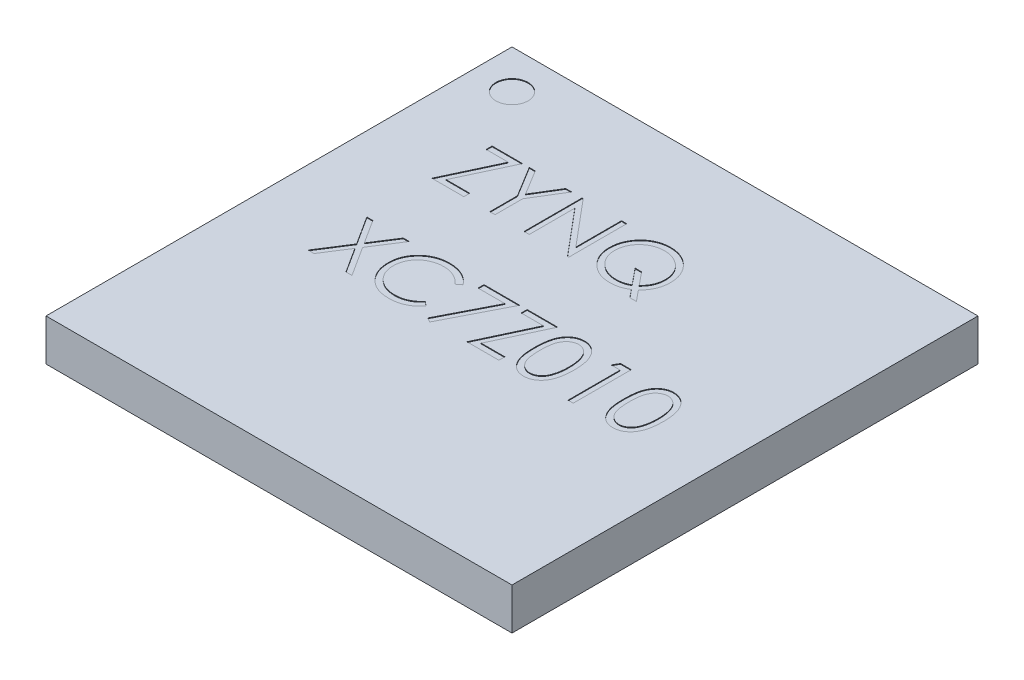
from build123d import *

# Parameters (mm, degrees)
SKETCH1_W           = 17.00022
SKETCH1_H           = 17.00022
BOSS_EXTRUDE1_DEPTH = 1.52
SKETCH2_R           = 0.585111635
CUT_EXTRUDE1_DEPTH  = 0.0254


with BuildPart() as part:
    # Sketch1 → Boss-Extrude1 (new body)
    with BuildSketch(Plane(origin=(0, 0, 0), x_dir=(1, 0, 0), z_dir=(0, 1, 0))):
        with Locations((8.50011, 8.50011)):
            Rectangle(SKETCH1_W, SKETCH1_H)
    extrude(amount=BOSS_EXTRUDE1_DEPTH)

    # Sketch2 → Cut-Extrude1 (cut)
    with BuildSketch(Plane(origin=(0, 1.52, 0), x_dir=(1, 0, 0), z_dir=(0, 1, 0))):
        with Locations((1.413411419, 15.586808581)):
            Circle(SKETCH2_R)
        Polygon((2.767351201, 13.289195865), (2.767351201, 13.506289882), (3.879958038, 13.506289882), (2.992077429, 11.606717233), (3.852821286, 11.606717233), (3.852821286, 11.389623216), (2.685940944, 11.389623216), (3.573821553, 13.289195865), align=None)
        Polygon((4.124188808, 13.506289882), (4.341706836, 13.506289882), (4.898010255, 12.596784674), (5.45346565, 13.506289882), (5.670983679, 13.506289882), (4.992564876, 12.395803104), (4.992564876, 11.389623216), (4.802607611, 11.389623216), (4.802607611, 12.395803104), align=None)
        Polygon((6.050898209, 11.389623216), (6.050898209, 13.506289882), (6.090755314, 13.506289882), (7.489146072, 11.840347708), (7.489146072, 13.506289882), (7.679103337, 13.506289882), (7.679103337, 11.389623216), (7.635854139, 11.389623216), (6.240855474, 13.051749284), (6.240855474, 11.389623216), align=None)
        with BuildLine():
            Line((9.986151281, 11.62537375), (10.311368295, 11.226802703))
            Line((10.311368295, 11.226802703), (10.074345725, 11.226802703))
            Line((10.074345725, 11.226802703), (9.839443215, 11.514282671))
            add(Edge.make_bspline(
                [(9.839443215, 11.514282671), (9.815883449, 11.499965697), (9.769197908, 11.471595481), (9.69640475, 11.435027847), (9.622163998, 11.404598805), (9.546639914, 11.379458868), (9.469942504, 11.359335824), (9.391682844, 11.34536958), (9.312144773, 11.337259556), (9.258706559, 11.335988753), (9.231834374, 11.335349711)],
                knots=[0, 0, 0, 0, 8.2682e-05, 0.000163842, 0.000244078, 0.000323188, 0.000402479, 0.000481742, 0.000561441, 0.000642058, 0.000642058, 0.000642058, 0.000642058], degree=3))
            add(Edge.make_bspline(
                [(9.231834374, 11.335349711), (9.193335025, 11.336277021), (9.117579767, 11.33810169), (9.006321648, 11.354031395), (8.899530602, 11.378633423), (8.797419487, 11.414230111), (8.69987707, 11.459697612), (8.606948667, 11.515752555), (8.518587047, 11.581618514), (8.436096562, 11.656865034), (8.360667381, 11.738722766), (8.294483001, 11.826184061), (8.238208396, 11.917797603), (8.192707025, 12.014020241), (8.156595607, 12.114014288), (8.131986654, 12.218611363), (8.116057566, 12.327188817), (8.114222496, 12.40111683), (8.113291372, 12.43862829)],
                knots=[0, 0, 0, 0, 0.000115443, 0.000227158, 0.000336486, 0.000443762, 0.000550937, 0.000658777, 0.000768766, 0.000881029, 0.000993265, 0.001102237, 0.001209571, 0.001315212, 0.001421029, 0.001527882, 0.001637077, 0.001749555, 0.001749555, 0.001749555, 0.001749555], degree=3))
            add(Edge.make_bspline(
                [(8.113291372, 12.43862829), (8.113622656, 12.463805305), (8.114282896, 12.513982444), (8.121920526, 12.588299924), (8.133268152, 12.661393946), (8.149318928, 12.73296076), (8.170330732, 12.80329371), (8.195521717, 12.872254108), (8.226043947, 12.939664261), (8.260548588, 13.005386203), (8.299031161, 13.068850317), (8.3409511, 13.129153339), (8.386411534, 13.18570098), (8.435380279, 13.238467367), (8.48766177, 13.28756914), (8.542806428, 13.333814859), (8.601990046, 13.375484133), (8.663650587, 13.414234887), (8.728133836, 13.448310808), (8.794178502, 13.478773594), (8.862278634, 13.503490305), (8.931550628, 13.524551938), (9.002414749, 13.540631293), (9.07481577, 13.551895732), (9.148702755, 13.559607031), (9.198600233, 13.560242655), (9.22377815, 13.560563387)],
                knots=[0, 0, 0, 0, 7.5504e-05, 0.000150477, 0.000223882, 0.000297329, 0.00037031, 0.000443958, 0.000517405, 0.000592132, 0.000666523, 0.000739921, 0.000812299, 0.000884008, 0.000955696, 0.001027357, 0.001099716, 0.001172662, 0.001245692, 0.001318366, 0.001390673, 0.001462843, 0.001535463, 0.001608448, 0.001682577, 0.001758081, 0.001758081, 0.001758081, 0.001758081], degree=3))
            add(Edge.make_bspline(
                [(9.22377815, 13.560563387), (9.262277643, 13.559640733), (9.337893111, 13.557828581), (9.448875606, 13.541896474), (9.555352051, 13.517195723), (9.657246645, 13.481780445), (9.754468542, 13.43619844), (9.846976897, 13.380154795), (9.934915134, 13.314284473), (10.01697458, 13.239032915), (10.092226111, 13.156973473), (10.158096537, 13.069035247), (10.214139803, 12.976526843), (10.259723207, 12.87930513), (10.295133222, 12.77740984), (10.319885779, 12.670799494), (10.335741814, 12.559664263), (10.337573945, 12.483910876), (10.338505047, 12.445412479)],
                knots=[0, 0, 0, 0, 0.000115443, 0.000226738, 0.000335653, 0.000442929, 0.00054972, 0.000657197, 0.000766846, 0.000878796, 0.000990745, 0.001100395, 0.001207872, 0.001314663, 0.001421939, 0.001530854, 0.001642568, 0.001758012, 0.001758012, 0.001758012, 0.001758012], degree=3))
            add(Edge.make_bspline(
                [(10.338505047, 12.445412479), (10.337487464, 12.405354643), (10.335486444, 12.326583177), (10.31845742, 12.211073214), (10.29107774, 12.100733989), (10.252250047, 11.995637797), (10.202054614, 11.89580374), (10.141461181, 11.800233467), (10.069740195, 11.708933755), (10.014307686, 11.653520417), (9.986151281, 11.62537375)],
                knots=[0, 0, 0, 0, 0.000120122, 0.000236213, 0.000349437, 0.000460652, 0.000571582, 0.000684037, 0.000799659, 0.000919012, 0.000919012, 0.000919012, 0.000919012], degree=3))
        make_face()
        with BuildLine():
            add(Edge.make_bspline(
                [(9.858523743, 11.781834086), (9.881618803, 11.805288551), (9.927047809, 11.851424523), (9.98599105, 11.927085076), (10.036688151, 12.005732688), (10.0772767, 12.088413558), (10.109570424, 12.174091818), (10.131881841, 12.263446348), (10.14585189, 12.356070364), (10.147642544, 12.419074069), (10.148547782, 12.450924631)],
                knots=[0, 0, 0, 0, 9.8678e-05, 0.000194104, 0.000287145, 0.000378924, 0.00046989, 0.000561313, 0.000654738, 0.000750255, 0.000750255, 0.000750255, 0.000750255], degree=3))
            add(Edge.make_bspline(
                [(10.148547782, 12.450924631), (10.148311257, 12.471435998), (10.147843688, 12.511983355), (10.141414631, 12.571986329), (10.132319427, 12.63066406), (10.11915236, 12.687911706), (10.102196413, 12.743613281), (10.081254329, 12.79769317), (10.056734131, 12.850325837), (10.028148938, 12.901184332), (9.996636182, 12.950194941), (9.961558618, 12.996758288), (9.923409983, 13.040634279), (9.882607033, 13.082545969), (9.838363089, 13.121629404), (9.790836826, 13.157867831), (9.740613874, 13.19213821), (9.68744571, 13.223071651), (9.632655933, 13.251510123), (9.576565138, 13.276136079), (9.519644304, 13.296993382), (9.461981574, 13.313905976), (9.403651566, 13.327218342), (9.344552014, 13.336303368), (9.28483575, 13.342725805), (9.244713142, 13.343221303), (9.224626174, 13.34346937)],
                knots=[0, 0, 0, 0, 6.1505e-05, 0.000121585, 0.000180837, 0.000239569, 0.000297646, 0.000355364, 0.000413409, 0.000471684, 0.000530255, 0.00058809, 0.000646406, 0.000704575, 0.00076345, 0.000823324, 0.000883772, 0.00094573, 0.001007742, 0.001068876, 0.001129373, 0.001189481, 0.00124904, 0.001308711, 0.001368791, 0.001429024, 0.001429024, 0.001429024, 0.001429024], degree=3))
            add(Edge.make_bspline(
                [(9.224626174, 13.34346937), (9.204398242, 13.343219572), (9.163994336, 13.34272062), (9.103989772, 13.33633889), (9.044754586, 13.32720834), (8.986549307, 13.313962139), (8.92916781, 13.297016654), (8.872788201, 13.276033258), (8.816920174, 13.252015552), (8.762723044, 13.223595238), (8.710291635, 13.1923958), (8.660426048, 13.158466181), (8.613809655, 13.121467864), (8.570000254, 13.081996518), (8.529107267, 13.039747593), (8.490937617, 12.995002126), (8.45616163, 12.947240934), (8.424300284, 12.897318539), (8.396139716, 12.845180701), (8.370742456, 12.791768112), (8.35011424, 12.736491904), (8.333178912, 12.679794507), (8.319340185, 12.621816875), (8.310420589, 12.562222449), (8.303943307, 12.501383255), (8.303481976, 12.460270843), (8.303248637, 12.439476314)],
                knots=[0, 0, 0, 0, 6.0657e-05, 0.000121159, 0.00018083, 0.000240388, 0.00030009, 0.000360189, 0.000420765, 0.0004824, 0.000543628, 0.000603726, 0.000663192, 0.000722033, 0.000780505, 0.000839466, 0.000898323, 0.000957607, 0.001016996, 0.001075988, 0.001134895, 0.001193784, 0.001253437, 0.001313528, 0.001374451, 0.001436804, 0.001436804, 0.001436804, 0.001436804], degree=3))
            add(Edge.make_bspline(
                [(8.303248637, 12.439476314), (8.304043026, 12.408903839), (8.305605834, 12.348758323), (8.318561131, 12.260454325), (8.340282311, 12.175916781), (8.370671144, 12.09502475), (8.408820156, 12.017311985), (8.456261337, 11.943539812), (8.512792289, 11.873989219), (8.576274423, 11.808182488), (8.646105717, 11.748564225), (8.720133662, 11.696093644), (8.797726225, 11.651577005), (8.879127058, 11.615646883), (8.963729154, 11.58679378), (9.052200359, 11.567259653), (9.143962334, 11.554311908), (9.206489519, 11.553072289), (9.23819455, 11.552443729)],
                knots=[0, 0, 0, 0, 9.1685e-05, 0.000180372, 0.000267067, 0.00035307, 0.00043916, 0.000526315, 0.000615579, 0.000707637, 0.000800262, 0.000890612, 0.000979493, 0.001068136, 0.001157169, 0.001247173, 0.001339582, 0.001434637, 0.001434637, 0.001434637, 0.001434637], degree=3))
            add(Edge.make_bspline(
                [(9.23819455, 11.552443729), (9.259977109, 11.552681019), (9.303061471, 11.553150364), (9.366594131, 11.559549119), (9.428572082, 11.568555499), (9.488421392, 11.58225332), (9.546661046, 11.599282724), (9.602944386, 11.619997457), (9.657569973, 11.644554947), (9.692303305, 11.663982812), (9.709695618, 11.67371109)],
                knots=[0, 0, 0, 0, 6.532e-05, 0.000129198, 0.000191383, 0.000253103, 0.000313211, 0.00037331, 0.000432895, 0.000492657, 0.000492657, 0.000492657, 0.000492657], degree=3))
            Line((9.709695618, 11.67371109), (9.233106409, 12.257999284))
            Line((9.233106409, 12.257999284), (9.470128978, 12.257999284))
            Line((9.470128978, 12.257999284), (9.858523743, 11.781834086))
        make_face(mode=Mode.SUBTRACT)
        Polygon((2.726646072, 8.978512105), (2.945860148, 8.978512105), (3.500043508, 8.112680107), (4.054226868, 8.978512105), (4.273440944, 8.978512105), (3.609862552, 7.941379359), (4.300577696, 6.861845438), (4.081363621, 6.861845438), (3.500043508, 7.770078611), (2.918723396, 6.861845438), (2.69950932, 6.861845438), (3.390648476, 7.941379359), align=None)
        with BuildLine():
            Line((6.620770004, 8.59011734), (6.454557397, 8.462913814))
            add(Edge.make_bspline(
                [(6.454557397, 8.462913814), (6.442700503, 8.477044662), (6.419146571, 8.505115845), (6.381252672, 8.54453395), (6.341760726, 8.581463894), (6.300685829, 8.616081602), (6.257288647, 8.647176503), (6.21262045, 8.676369028), (6.165934013, 8.702535707), (6.101374631, 8.734263323), (6.016920932, 8.767371712), (5.91060691, 8.795132237), (5.799626389, 8.812804091), (5.72391165, 8.814718067), (5.685400079, 8.815691592)],
                knots=[0, 0, 0, 0, 5.5327e-05, 0.000109907, 0.000163905, 0.000217489, 0.000270921, 0.000323963, 0.000377503, 0.000431357, 0.000539703, 0.000648928, 0.000760468, 0.000875931, 0.000875931, 0.000875931, 0.000875931], degree=3))
            add(Edge.make_bspline(
                [(5.685400079, 8.815691592), (5.664183036, 8.815447291), (5.621945864, 8.814960956), (5.559263216, 8.808544961), (5.497751037, 8.799527229), (5.437449341, 8.786146677), (5.378434885, 8.769229902), (5.320321861, 8.749015485), (5.263951641, 8.724005653), (5.208544421, 8.696363039), (5.155458898, 8.665140727), (5.105230369, 8.631084557), (5.058042027, 8.594575628), (5.013856542, 8.555477101), (4.972628745, 8.513965059), (4.934657371, 8.4695971), (4.900073814, 8.422515071), (4.868192565, 8.37333982), (4.839640103, 8.322214584), (4.815733938, 8.268950136), (4.794564173, 8.214458607), (4.777812726, 8.158124334), (4.764553614, 8.100343709), (4.755404979, 8.040961661), (4.749061952, 7.980102245), (4.748578035, 7.938851851), (4.748334107, 7.918058713)],
                knots=[0, 0, 0, 0, 6.3624e-05, 0.000126658, 0.000188844, 0.000250057, 0.000311794, 0.000372946, 0.000434469, 0.000496666, 0.000558624, 0.000619072, 0.00067861, 0.000737485, 0.000795951, 0.000853991, 0.000912506, 0.000971077, 0.001029722, 0.001087974, 0.001146089, 0.001204978, 0.001264122, 0.001323793, 0.001385139, 0.001447492, 0.001447492, 0.001447492, 0.001447492], degree=3))
            add(Edge.make_bspline(
                [(4.748334107, 7.918058713), (4.749097207, 7.886773581), (4.750595453, 7.825349375), (4.763929445, 7.735378577), (4.784192048, 7.649187503), (4.814560516, 7.567314932), (4.852006799, 7.488751306), (4.89932374, 7.414825904), (4.95412517, 7.3444216), (5.017186366, 7.279202294), (5.086374645, 7.219624946), (5.160607906, 7.167161499), (5.239701261, 7.123428213), (5.322781414, 7.087036093), (5.410487683, 7.059061786), (5.502662349, 7.039368245), (5.599104937, 7.026521783), (5.665005478, 7.025291886), (5.698544443, 7.024665951)],
                knots=[0, 0, 0, 0, 9.3802e-05, 0.000184169, 0.000272303, 0.000358955, 0.000445621, 0.000532905, 0.000621711, 0.000712875, 0.00080458, 0.000895277, 0.000985057, 0.001075253, 0.001166973, 0.001260703, 0.001357736, 0.001458299, 0.001458299, 0.001458299, 0.001458299], degree=3))
            add(Edge.make_bspline(
                [(5.698544443, 7.024665951), (5.735497022, 7.02568726), (5.808228536, 7.027697442), (5.9148892, 7.044727083), (6.016994639, 7.072339253), (6.114550346, 7.110982282), (6.207281299, 7.161217004), (6.295332612, 7.222115244), (6.37877861, 7.294256283), (6.428956481, 7.349339889), (6.454557397, 7.377443729)],
                knots=[0, 0, 0, 0, 0.000110804, 0.000218089, 0.000323109, 0.000427593, 0.000532126, 0.000638803, 0.000748216, 0.000862188, 0.000862188, 0.000862188, 0.000862188], degree=3))
            Line((6.454557397, 7.377443729), (6.620770004, 7.251512238))
            add(Edge.make_bspline(
                [(6.620770004, 7.251512238), (6.607393814, 7.23425327), (6.580705505, 7.199818002), (6.537490418, 7.15127273), (6.491965576, 7.105610766), (6.443792837, 7.063200252), (6.393526363, 7.023192551), (6.340263584, 6.986724301), (6.284704693, 6.95328648), (6.227037937, 6.922669245), (6.167324585, 6.895505005), (6.105636189, 6.872249631), (6.04223865, 6.85221696), (5.977129071, 6.835736027), (5.910172399, 6.822872086), (5.841610256, 6.814272568), (5.771294664, 6.808381029), (5.723856281, 6.807844052), (5.699816478, 6.807571934)],
                knots=[0, 0, 0, 0, 6.5492e-05, 0.00013067, 0.000194831, 0.000258812, 0.000323113, 0.000387446, 0.000452311, 0.000517559, 0.000583215, 0.000648971, 0.000715217, 0.000782576, 0.000850351, 0.000919615, 0.000989794, 0.001061896, 0.001061896, 0.001061896, 0.001061896], degree=3))
            add(Edge.make_bspline(
                [(5.699816478, 6.807571934), (5.677051023, 6.807730377), (5.632035153, 6.808043678), (5.565572575, 6.813118942), (5.500869352, 6.820043306), (5.438110412, 6.830469481), (5.376953274, 6.842772963), (5.317952349, 6.85926558), (5.260527055, 6.877740552), (5.204908107, 6.89945452), (5.151048193, 6.923957164), (5.099121031, 6.951650154), (5.049150503, 6.982300615), (5.000645319, 7.015232931), (4.954322019, 7.051504918), (4.909779173, 7.090612835), (4.866767008, 7.13242487), (4.840155861, 7.162575187), (4.826776281, 7.177734193)],
                knots=[0, 0, 0, 0, 6.8278e-05, 0.000135011, 0.000199862, 0.000263436, 0.000325805, 0.000386905, 0.00044711, 0.000506717, 0.000565916, 0.000624529, 0.000683141, 0.00074171, 0.000800319, 0.000859512, 0.00091948, 0.000980118, 0.000980118, 0.000980118, 0.000980118], degree=3))
            add(Edge.make_bspline(
                [(4.826776281, 7.177734193), (4.805346154, 7.204066246), (4.762744622, 7.256412447), (4.708240042, 7.341252064), (4.66158414, 7.429830457), (4.623861559, 7.522612985), (4.594371716, 7.619391453), (4.573942136, 7.720214645), (4.560666642, 7.8249884), (4.559148515, 7.896251601), (4.558376842, 7.932475112)],
                knots=[0, 0, 0, 0, 0.000101785, 0.000202341, 0.000301912, 0.000401753, 0.000502352, 0.000604968, 0.000710047, 0.000818677, 0.000818677, 0.000818677, 0.000818677], degree=3))
            add(Edge.make_bspline(
                [(4.558376842, 7.932475112), (4.559317364, 7.970548172), (4.561167781, 8.045454541), (4.576889048, 8.155384503), (4.602179463, 8.260704635), (4.638100439, 8.361218328), (4.683642246, 8.457454259), (4.739901198, 8.548677274), (4.806223708, 8.635470767), (4.882089618, 8.716517783), (4.965285102, 8.790624915), (5.054377908, 8.855822), (5.149193657, 8.910079736), (5.248687787, 8.955434558), (5.353605318, 8.990295734), (5.463722403, 9.014699804), (5.578832128, 9.029889679), (5.657367976, 9.031809923), (5.697272408, 9.032785609)],
                knots=[0, 0, 0, 0, 0.000114173, 0.000224627, 0.000332404, 0.00043862, 0.000544262, 0.000651234, 0.000759531, 0.000871432, 0.000983759, 0.001093336, 0.001201992, 0.001310916, 0.001420865, 0.001532991, 0.001648852, 0.001768532, 0.001768532, 0.001768532, 0.001768532], degree=3))
            add(Edge.make_bspline(
                [(5.697272408, 9.032785609), (5.721592589, 9.03249403), (5.769731937, 9.031916879), (5.840944255, 9.026288879), (5.910275567, 9.016906841), (5.977773637, 9.004136646), (6.043766839, 8.988287457), (6.107750794, 8.967640705), (6.170100952, 8.944032898), (6.230424082, 8.91684373), (6.288430758, 8.886323368), (6.344102912, 8.85281011), (6.396998327, 8.816345503), (6.447489202, 8.777239678), (6.494730911, 8.734665311), (6.540064757, 8.689793432), (6.581951219, 8.641331548), (6.607806722, 8.607219993), (6.620770004, 8.59011734)],
                knots=[0, 0, 0, 0, 7.295e-05, 0.000144397, 0.000214137, 0.000282745, 0.000350413, 0.000417596, 0.000484295, 0.000550337, 0.000615961, 0.000680825, 0.000745159, 0.000808602, 0.000872266, 0.000935828, 0.000999848, 0.001064221, 0.001064221, 0.001064221, 0.001064221], degree=3))
        make_face()
        Polygon((7.000684534, 8.978512105), (8.303248637, 8.978512105), (7.190641799, 6.807571934), (7.026549251, 6.897886437), (7.981847728, 8.761418088), (7.000684534, 8.761418088), align=None)
        Polygon((8.574616158, 8.761418088), (8.574616158, 8.978512105), (9.687222996, 8.978512105), (8.799342387, 7.078939455), (9.660086243, 7.078939455), (9.660086243, 6.861845438), (8.493205902, 6.861845438), (9.381086511, 8.761418088), align=None)
        with BuildLine():
            add(Edge.make_bspline(
                [(9.904317013, 7.919330748), (9.904515386, 7.953256311), (9.904900728, 8.019157206), (9.909187535, 8.115184109), (9.916308813, 8.205269617), (9.926068081, 8.289418042), (9.937944384, 8.36765111), (9.953798511, 8.439759748), (9.971828159, 8.506077701), (9.992724162, 8.566821225), (10.016302491, 8.622808693), (10.041965116, 8.675075363), (10.070730491, 8.72354215), (10.100954624, 8.768982624), (10.133860972, 8.810652953), (10.168513098, 8.849141611), (10.206263471, 8.883559065), (10.245828814, 8.914913734), (10.287567342, 8.942399843), (10.330289336, 8.966610118), (10.374288852, 8.987292895), (10.41968602, 9.003555206), (10.466072805, 9.01698748), (10.513611364, 9.026173177), (10.562380189, 9.031952831), (10.595298247, 9.032505383), (10.611992627, 9.032785609)],
                knots=[0, 0, 0, 0, 0.000101771, 0.000197691, 0.000288293, 0.000372812, 0.000451793, 0.000525562, 0.000594175, 0.000657869, 0.000718111, 0.000776326, 0.000832393, 0.000887078, 0.000939923, 0.000991548, 0.001042261, 0.001092987, 0.001142849, 0.001192024, 0.001240207, 0.001288496, 0.001336546, 0.001384942, 0.001433593, 0.001483655, 0.001483655, 0.001483655, 0.001483655], degree=3))
            add(Edge.make_bspline(
                [(10.611992627, 9.032785609), (10.628826464, 9.032490597), (10.662303669, 9.031903911), (10.711797611, 9.026265145), (10.760148132, 9.0169088), (10.807149102, 9.003651829), (10.853186594, 8.98720492), (10.897900516, 8.96659033), (10.941568609, 8.942594063), (10.983496925, 8.914397718), (11.024145764, 8.882960818), (11.062516675, 8.847423394), (11.098613151, 8.808144278), (11.132888217, 8.765543722), (11.164369459, 8.718804647), (11.194349582, 8.668739971), (11.221184099, 8.614474163), (11.247028403, 8.556912642), (11.269336247, 8.494462715), (11.289454405, 8.427476407), (11.305709781, 8.355162494), (11.31924996, 8.277900384), (11.329739492, 8.195406334), (11.337379233, 8.107857182), (11.341414861, 8.015195326), (11.342174866, 7.95184177), (11.342564876, 7.919330748)],
                knots=[0, 0, 0, 0, 5.0486e-05, 0.000100401, 0.000149214, 0.00019808, 0.000246767, 0.00029572, 0.000345635, 0.000396085, 0.000447145, 0.000499655, 0.000552765, 0.000607065, 0.000663516, 0.000721691, 0.000781991, 0.00084502, 0.000910878, 0.000980773, 0.001054728, 0.001133082, 0.00121602, 0.001304122, 0.001396653, 0.001494191, 0.001494191, 0.001494191, 0.001494191], degree=3))
            add(Edge.make_bspline(
                [(11.342564876, 7.919330748), (11.342170822, 7.886961527), (11.341403025, 7.823891421), (11.337424474, 7.731646498), (11.329587587, 7.644561967), (11.319784404, 7.562428973), (11.306206917, 7.485589365), (11.289512364, 7.413777247), (11.270976216, 7.346682499), (11.248095174, 7.284854779), (11.223051554, 7.227431594), (11.195803888, 7.173809081), (11.166612136, 7.123513275), (11.134808466, 7.076946762), (11.100909497, 7.033779669), (11.064189692, 6.994773964), (11.025684148, 6.958989796), (10.984915687, 6.927148097), (10.942333463, 6.899277763), (10.898815354, 6.874353196), (10.853589213, 6.854255328), (10.807679951, 6.836998423), (10.760430891, 6.82381434), (10.711900931, 6.814698246), (10.662336922, 6.808304795), (10.628832166, 6.807817067), (10.611992627, 6.807571934)],
                knots=[0, 0, 0, 0, 9.7114e-05, 0.000189222, 0.000276901, 0.000359365, 0.000437302, 0.000510843, 0.000580501, 0.000645961, 0.000708431, 0.000768353, 0.000826312, 0.000882763, 0.000937395, 0.000990794, 0.001043304, 0.001094959, 0.001145763, 0.001195884, 0.001245223, 0.001294056, 0.001342922, 0.001392151, 0.001442115, 0.001492601, 0.001492601, 0.001492601, 0.001492601], degree=3))
            add(Edge.make_bspline(
                [(10.611992627, 6.807571934), (10.59529871, 6.807853968), (10.562381565, 6.808410084), (10.513606051, 6.814163626), (10.466263811, 6.823413764), (10.420121232, 6.83636571), (10.374941577, 6.852219444), (10.33134049, 6.872874291), (10.288833176, 6.896662038), (10.247533045, 6.923752602), (10.208216166, 6.954790001), (10.170661295, 6.98911888), (10.135811879, 7.027595896), (10.103376021, 7.069613497), (10.072548835, 7.114785124), (10.044191928, 7.163727521), (10.017962888, 7.216246624), (9.993988015, 7.272681741), (9.972731442, 7.333856388), (9.953954971, 7.400470415), (9.939129742, 7.473111776), (9.92644005, 7.551197041), (9.916204828, 7.635061751), (9.909217212, 7.724751436), (9.904898417, 7.820210205), (9.904514351, 7.88568764), (9.904317013, 7.919330748)],
                knots=[0, 0, 0, 0, 5.0062e-05, 9.8713e-05, 0.00014711, 0.000194637, 0.000242383, 0.000290566, 0.000339163, 0.000388437, 0.000438568, 0.000489281, 0.000540906, 0.000594085, 0.000648418, 0.000704852, 0.000763635, 0.000824433, 0.000888666, 0.000957801, 0.001031897, 0.001110945, 0.001195093, 0.001285272, 0.001380769, 0.001481691, 0.001481691, 0.001481691, 0.001481691], degree=3))
        make_face()
        with BuildLine():
            add(Edge.make_bspline(
                [(10.094274278, 7.920178771), (10.094346515, 7.891906939), (10.094486713, 7.837036864), (10.098149272, 7.757303083), (10.103138698, 7.682935312), (10.109574149, 7.613839126), (10.11913117, 7.550248404), (10.129839561, 7.491725786), (10.142871025, 7.438580981), (10.15828944, 7.390449305), (10.17585118, 7.346513916), (10.195025678, 7.305631276), (10.215624306, 7.267318439), (10.238677316, 7.231919542), (10.263784045, 7.199319148), (10.290377397, 7.168940244), (10.319449864, 7.141848737), (10.359668794, 7.109356781), (10.412764758, 7.075780924), (10.479663795, 7.046543051), (10.548406144, 7.028168899), (10.595064281, 7.025832246), (10.618352803, 7.024665951)],
                knots=[0, 0, 0, 0, 8.4807e-05, 0.000164593, 0.000239392, 0.000308416, 0.000372699, 0.000432242, 0.000486849, 0.000536731, 0.000583737, 0.000628692, 0.000672143, 0.000714128, 0.00075526, 0.000795507, 0.000835102, 0.000874304, 0.000950532, 0.001022689, 0.001092723, 0.001162513, 0.001162513, 0.001162513, 0.001162513], degree=3))
            add(Edge.make_bspline(
                [(10.618352803, 7.024665951), (10.641791967, 7.025632228), (10.6886219, 7.027562787), (10.75704091, 7.04618869), (10.823462073, 7.074291697), (10.875515103, 7.107521855), (10.915116451, 7.139168035), (10.94349006, 7.166149275), (10.969532346, 7.19636068), (10.994232077, 7.228956921), (11.016885899, 7.264560757), (11.037485987, 7.303000981), (11.056284011, 7.344384341), (11.066993768, 7.373273659), (11.07246939, 7.388044022)],
                knots=[0, 0, 0, 0, 7.0179e-05, 0.000140213, 0.000211255, 0.000285954, 0.00032456, 0.000363247, 0.000403215, 0.00044409, 0.000485846, 0.000529669, 0.000574832, 0.000622078, 0.000622078, 0.000622078, 0.000622078], degree=3))
            add(Edge.make_bspline(
                [(11.07246939, 7.388044022), (11.078850697, 7.406930579), (11.091807487, 7.445278389), (11.108506036, 7.504764978), (11.121656825, 7.567178079), (11.133488004, 7.632144697), (11.141563423, 7.700143945), (11.148063291, 7.770965424), (11.15189185, 7.844662534), (11.152366437, 7.89473379), (11.152607611, 7.920178771)],
                knots=[0, 0, 0, 0, 5.9802e-05, 0.000121424, 0.000185214, 0.00025109, 0.00031946, 0.000390555, 0.000464431, 0.000540764, 0.000540764, 0.000540764, 0.000540764], degree=3))
            add(Edge.make_bspline(
                [(11.152607611, 7.920178771), (11.152274877, 7.945619637), (11.15162398, 7.995387408), (11.149135997, 8.068272212), (11.142711263, 8.137497953), (11.135575606, 8.203362858), (11.125054429, 8.265502327), (11.113710422, 8.324436559), (11.098469689, 8.379435436), (11.082189635, 8.43136004), (11.063556681, 8.479620436), (11.043045737, 8.524441631), (11.021140197, 8.566040012), (10.997347509, 8.604301448), (10.97195012, 8.639397319), (10.944277697, 8.670623955), (10.91542791, 8.698949169), (10.875019421, 8.731281294), (10.822118303, 8.764247891), (10.756292602, 8.794586231), (10.687790832, 8.812008389), (10.641482124, 8.814464743), (10.618352803, 8.815691592)],
                knots=[0, 0, 0, 0, 7.6333e-05, 0.000149323, 0.000218691, 0.000284855, 0.00034801, 0.000407716, 0.0004648, 0.000519108, 0.000570921, 0.000619874, 0.000666914, 0.00071186, 0.000754942, 0.000796705, 0.000836885, 0.000876087, 0.000951731, 0.001023283, 0.001092802, 0.00116217, 0.00116217, 0.00116217, 0.00116217], degree=3))
            add(Edge.make_bspline(
                [(10.618352803, 8.815691592), (10.594942112, 8.81446305), (10.54807808, 8.812003729), (10.478864317, 8.794651142), (10.412519305, 8.764405206), (10.359758077, 8.731172104), (10.319321406, 8.699519887), (10.290847587, 8.672071889), (10.264149664, 8.642047726), (10.239555388, 8.60914752), (10.21652044, 8.573789893), (10.195365257, 8.535696688), (10.176304776, 8.494674863), (10.158715557, 8.450759209), (10.143250109, 8.402631685), (10.130493283, 8.349552342), (10.118708256, 8.291215864), (10.110365403, 8.227280733), (10.102948751, 8.158167241), (10.098182412, 8.083613815), (10.094474461, 8.003746308), (10.094342342, 7.948592532), (10.094274278, 7.920178771)],
                knots=[0, 0, 0, 0, 7.0213e-05, 0.000140555, 0.000212494, 0.000288137, 0.000327075, 0.000366362, 0.000406609, 0.000447484, 0.00048947, 0.000533125, 0.00057808, 0.000625086, 0.000674968, 0.000729575, 0.000788782, 0.000853424, 0.000922913, 0.000997289, 0.001077499, 0.00116273, 0.00116273, 0.00116273, 0.00116273], degree=3))
        make_face(mode=Mode.SUBTRACT)
        Polygon((11.98239861, 8.978512105), (12.373761457, 8.978512105), (12.373761457, 6.861845438), (12.183804192, 6.861845438), (12.183804192, 8.761418088), (11.858163167, 8.761418088), align=None)
        with BuildLine():
            add(Edge.make_bspline(
                [(13.160727269, 7.919330748), (13.160925642, 7.953256311), (13.161310984, 8.019157206), (13.165597791, 8.115184109), (13.17271907, 8.205269617), (13.182478338, 8.289418042), (13.19435464, 8.36765111), (13.210208768, 8.439759748), (13.228238415, 8.506077701), (13.249134418, 8.566821225), (13.272712748, 8.622808693), (13.298375372, 8.675075363), (13.327140748, 8.72354215), (13.357364881, 8.768982624), (13.390271229, 8.810652953), (13.424923354, 8.849141611), (13.462673727, 8.883559065), (13.50223907, 8.914913734), (13.543977599, 8.942399843), (13.586699592, 8.966610118), (13.630699109, 8.987292895), (13.676096276, 9.003555206), (13.722483061, 9.01698748), (13.770021621, 9.026173177), (13.818790446, 9.031952831), (13.851708504, 9.032505383), (13.868402883, 9.032785609)],
                knots=[0, 0, 0, 0, 0.000101771, 0.000197691, 0.000288293, 0.000372812, 0.000451793, 0.000525562, 0.000594175, 0.000657869, 0.000718111, 0.000776326, 0.000832393, 0.000887078, 0.000939923, 0.000991548, 0.001042261, 0.001092987, 0.001142849, 0.001192024, 0.001240207, 0.001288496, 0.001336546, 0.001384942, 0.001433593, 0.001483655, 0.001483655, 0.001483655, 0.001483655], degree=3))
            add(Edge.make_bspline(
                [(13.868402883, 9.032785609), (13.88523672, 9.032490597), (13.918713926, 9.031903911), (13.968207867, 9.026265145), (14.016558389, 9.0169088), (14.063559358, 9.003651829), (14.10959685, 8.98720492), (14.154310773, 8.96659033), (14.197978865, 8.942594063), (14.239907182, 8.914397718), (14.280556021, 8.882960818), (14.318926932, 8.847423394), (14.355023407, 8.808144278), (14.389298473, 8.765543722), (14.420779715, 8.718804647), (14.450759838, 8.668739971), (14.477594355, 8.614474163), (14.503438659, 8.556912642), (14.525746503, 8.494462715), (14.545864661, 8.427476407), (14.562120037, 8.355162494), (14.575660216, 8.277900384), (14.586149749, 8.195406334), (14.593789489, 8.107857182), (14.597825117, 8.015195326), (14.598585122, 7.95184177), (14.598975132, 7.919330748)],
                knots=[0, 0, 0, 0, 5.0486e-05, 0.000100401, 0.000149214, 0.00019808, 0.000246767, 0.00029572, 0.000345635, 0.000396085, 0.000447145, 0.000499655, 0.000552765, 0.000607065, 0.000663516, 0.000721691, 0.000781991, 0.00084502, 0.000910878, 0.000980773, 0.001054728, 0.001133082, 0.00121602, 0.001304122, 0.001396653, 0.001494191, 0.001494191, 0.001494191, 0.001494191], degree=3))
            add(Edge.make_bspline(
                [(14.598975132, 7.919330748), (14.598581079, 7.886961527), (14.597813282, 7.823891421), (14.59383473, 7.731646498), (14.585997844, 7.644561967), (14.57619466, 7.562428973), (14.562617173, 7.485589365), (14.54592262, 7.413777247), (14.527386473, 7.346682499), (14.504505431, 7.284854779), (14.479461811, 7.227431594), (14.452214144, 7.173809081), (14.423022392, 7.123513275), (14.391218723, 7.076946762), (14.357319754, 7.033779669), (14.320599948, 6.994773964), (14.282094404, 6.958989796), (14.241325943, 6.927148097), (14.198743719, 6.899277763), (14.155225611, 6.874353196), (14.109999469, 6.854255328), (14.064090207, 6.836998423), (14.016841148, 6.82381434), (13.968311188, 6.814698246), (13.918747178, 6.808304795), (13.885242422, 6.807817067), (13.868402883, 6.807571934)],
                knots=[0, 0, 0, 0, 9.7114e-05, 0.000189222, 0.000276901, 0.000359365, 0.000437302, 0.000510843, 0.000580501, 0.000645961, 0.000708431, 0.000768353, 0.000826312, 0.000882763, 0.000937395, 0.000990794, 0.001043304, 0.001094959, 0.001145763, 0.001195884, 0.001245223, 0.001294056, 0.001342922, 0.001392151, 0.001442115, 0.001492601, 0.001492601, 0.001492601, 0.001492601], degree=3))
            add(Edge.make_bspline(
                [(13.868402883, 6.807571934), (13.851708967, 6.807853968), (13.818791822, 6.808410084), (13.770016307, 6.814163626), (13.722674068, 6.823413764), (13.676531488, 6.83636571), (13.631351834, 6.852219444), (13.587750746, 6.872874291), (13.545243433, 6.896662038), (13.503943301, 6.923752602), (13.464626423, 6.954790001), (13.427071552, 6.98911888), (13.392222136, 7.027595896), (13.359786278, 7.069613497), (13.328959091, 7.114785124), (13.300602184, 7.163727521), (13.274373144, 7.216246624), (13.250398271, 7.272681741), (13.229141698, 7.333856388), (13.210365227, 7.400470415), (13.195539999, 7.473111776), (13.182850307, 7.551197041), (13.172615085, 7.635061751), (13.165627469, 7.724751436), (13.161308673, 7.820210205), (13.160924607, 7.88568764), (13.160727269, 7.919330748)],
                knots=[0, 0, 0, 0, 5.0062e-05, 9.8713e-05, 0.00014711, 0.000194637, 0.000242383, 0.000290566, 0.000339163, 0.000388437, 0.000438568, 0.000489281, 0.000540906, 0.000594085, 0.000648418, 0.000704852, 0.000763635, 0.000824433, 0.000888666, 0.000957801, 0.001031897, 0.001110945, 0.001195093, 0.001285272, 0.001380769, 0.001481691, 0.001481691, 0.001481691, 0.001481691], degree=3))
        make_face()
        with BuildLine():
            add(Edge.make_bspline(
                [(13.350684534, 7.920178771), (13.350756771, 7.891906939), (13.350896969, 7.837036864), (13.354559528, 7.757303083), (13.359548954, 7.682935312), (13.365984406, 7.613839126), (13.375541427, 7.550248404), (13.386249818, 7.491725786), (13.399281281, 7.438580981), (13.414699697, 7.390449305), (13.432261436, 7.346513916), (13.451435935, 7.305631276), (13.472034563, 7.267318439), (13.495087573, 7.231919542), (13.520194301, 7.199319148), (13.546787653, 7.168940244), (13.575860121, 7.141848737), (13.616079051, 7.109356781), (13.669175014, 7.075780924), (13.736074051, 7.046543051), (13.8048164, 7.028168899), (13.851474537, 7.025832246), (13.87476306, 7.024665951)],
                knots=[0, 0, 0, 0, 8.4807e-05, 0.000164593, 0.000239392, 0.000308416, 0.000372699, 0.000432242, 0.000486849, 0.000536731, 0.000583737, 0.000628692, 0.000672143, 0.000714128, 0.00075526, 0.000795507, 0.000835102, 0.000874304, 0.000950532, 0.001022689, 0.001092723, 0.001162513, 0.001162513, 0.001162513, 0.001162513], degree=3))
            add(Edge.make_bspline(
                [(13.87476306, 7.024665951), (13.898202223, 7.025632228), (13.945032157, 7.027562787), (14.013451166, 7.04618869), (14.079872329, 7.074291697), (14.13192536, 7.107521855), (14.171526708, 7.139168035), (14.199900316, 7.166149275), (14.225942602, 7.19636068), (14.250642333, 7.228956921), (14.273296155, 7.264560757), (14.293896243, 7.303000981), (14.312694268, 7.344384341), (14.323404024, 7.373273659), (14.328879646, 7.388044022)],
                knots=[0, 0, 0, 0, 7.0179e-05, 0.000140213, 0.000211255, 0.000285954, 0.00032456, 0.000363247, 0.000403215, 0.00044409, 0.000485846, 0.000529669, 0.000574832, 0.000622078, 0.000622078, 0.000622078, 0.000622078], degree=3))
            add(Edge.make_bspline(
                [(14.328879646, 7.388044022), (14.335260953, 7.406930579), (14.348217744, 7.445278389), (14.364916293, 7.504764978), (14.378067082, 7.567178079), (14.38989826, 7.632144697), (14.39797368, 7.700143945), (14.404473548, 7.770965424), (14.408302106, 7.844662534), (14.408776694, 7.89473379), (14.409017867, 7.920178771)],
                knots=[0, 0, 0, 0, 5.9802e-05, 0.000121424, 0.000185214, 0.00025109, 0.00031946, 0.000390555, 0.000464431, 0.000540764, 0.000540764, 0.000540764, 0.000540764], degree=3))
            add(Edge.make_bspline(
                [(14.409017867, 7.920178771), (14.408685134, 7.945619637), (14.408034236, 7.995387408), (14.405546253, 8.068272212), (14.39912152, 8.137497953), (14.391985862, 8.203362858), (14.381464686, 8.265502327), (14.370120679, 8.324436559), (14.354879946, 8.379435436), (14.338599891, 8.43136004), (14.319966938, 8.479620436), (14.299455994, 8.524441631), (14.277550454, 8.566040012), (14.253757765, 8.604301448), (14.228360376, 8.639397319), (14.200687954, 8.670623955), (14.171838166, 8.698949169), (14.131429678, 8.731281294), (14.07852856, 8.764247891), (14.012702859, 8.794586231), (13.944201088, 8.812008389), (13.89789238, 8.814464743), (13.87476306, 8.815691592)],
                knots=[0, 0, 0, 0, 7.6333e-05, 0.000149323, 0.000218691, 0.000284855, 0.00034801, 0.000407716, 0.0004648, 0.000519108, 0.000570921, 0.000619874, 0.000666914, 0.00071186, 0.000754942, 0.000796705, 0.000836885, 0.000876087, 0.000951731, 0.001023283, 0.001092802, 0.00116217, 0.00116217, 0.00116217, 0.00116217], degree=3))
            add(Edge.make_bspline(
                [(13.87476306, 8.815691592), (13.851352368, 8.81446305), (13.804488337, 8.812003729), (13.735274574, 8.794651142), (13.668929561, 8.764405206), (13.616168333, 8.731172104), (13.575731663, 8.699519887), (13.547257843, 8.672071889), (13.52055992, 8.642047726), (13.495965644, 8.60914752), (13.472930697, 8.573789893), (13.451775513, 8.535696688), (13.432715033, 8.494674863), (13.415125813, 8.450759209), (13.399660365, 8.402631685), (13.38690354, 8.349552342), (13.375118512, 8.291215864), (13.366775659, 8.227280733), (13.359359007, 8.158167241), (13.354592668, 8.083613815), (13.350884717, 8.003746308), (13.350752598, 7.948592532), (13.350684534, 7.920178771)],
                knots=[0, 0, 0, 0, 7.0213e-05, 0.000140555, 0.000212494, 0.000288137, 0.000327075, 0.000366362, 0.000406609, 0.000447484, 0.00048947, 0.000533125, 0.00057808, 0.000625086, 0.000674968, 0.000729575, 0.000788782, 0.000853424, 0.000922913, 0.000997289, 0.001077499, 0.00116273, 0.00116273, 0.00116273, 0.00116273], degree=3))
        make_face(mode=Mode.SUBTRACT)
    extrude(amount=-CUT_EXTRUDE1_DEPTH, mode=Mode.SUBTRACT)


solid = part.part
